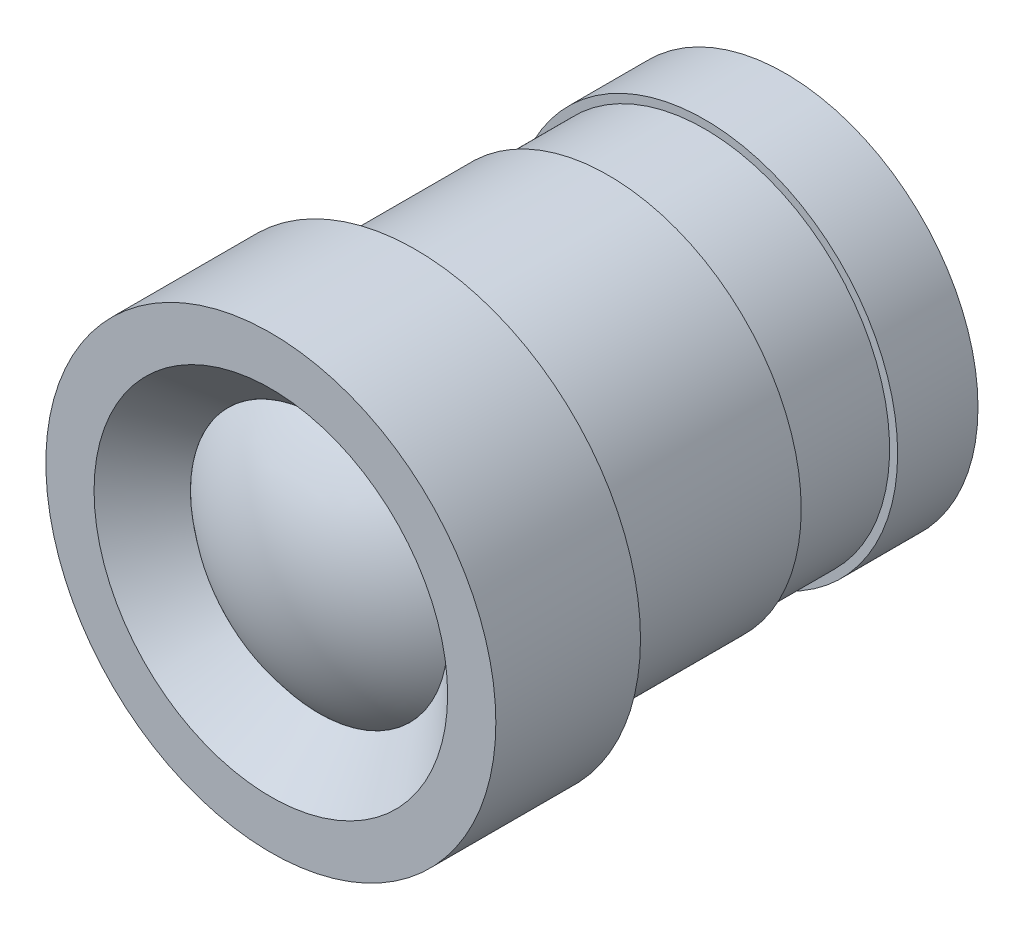
from build123d import *

# Parameters (mm, degrees)
SKETCH2_R          = 5.5
CUT_EXTRUDE1_DEPTH = 1.5
CUT_EXTRUDE1_TAPER = 45
SKETCH3_R          = 4
CUT_EXTRUDE2_DEPTH = 15.5
CUT_EXTRUDE3_START = -2.5
SKETCH6_R          = 6
SKETCH6_R_2        = 5.75
CUT_EXTRUDE3_DEPTH = 3


with BuildPart() as part:
    # Sketch1 → Revolve1 (revolve)
    with BuildSketch(Plane(origin=(0, 0, 0), x_dir=(0, 0, -1), z_dir=(1, 0, 0))):
        Polygon((-1.5, 0), (-1.5, 7), (3, 7), (3, 6), (14.5, 6), (14.5, 0), align=None)
    revolve(axis=Axis((0, 0, 1.5), (0, 0, -1)))

    # Sketch2 → Cut-Extrude1 (cut)
    with BuildSketch(Plane.XY.offset(1.5)):
        Circle(SKETCH2_R)
    extrude(amount=-CUT_EXTRUDE1_DEPTH, taper=CUT_EXTRUDE1_TAPER, mode=Mode.SUBTRACT)

    # Sketch3 → Cut-Extrude2 (cut, through all)
    with BuildSketch(Plane.XY):
        Circle(SKETCH3_R)
    extrude(amount=-CUT_EXTRUDE2_DEPTH, mode=Mode.SUBTRACT)

    # Sketch6 → Cut-Extrude3 (cut)
    with BuildSketch(Plane(origin=(0, 0, -14.5), x_dir=(-1, 0, 0), z_dir=(0, 0, -1)).offset(CUT_EXTRUDE3_START)):
        Circle(SKETCH6_R)
        Circle(SKETCH6_R_2, mode=Mode.SUBTRACT)
    extrude(amount=-CUT_EXTRUDE3_DEPTH, mode=Mode.SUBTRACT)


with BuildPart() as body_2:
    # Sketch4 → Revolve3 (revolve)
    with BuildSketch(Plane(origin=(0, 0, 0), x_dir=(1, 0, 0), z_dir=(0, 1, 0))):
        with BuildLine():
            Line((4, 0), (4, 14.5))
            Line((4, 14.5), (0, 14.5))
            Line((0, 14.5), (0, -1.5))
            ThreePointArc((0, -1.5), (2.136000936, -1.112669164), (4, 0))
        make_face()
    revolve(axis=Axis((0, 0, 1.5), (0, 0, -1)))


solid = Compound([part.part, body_2.part])
